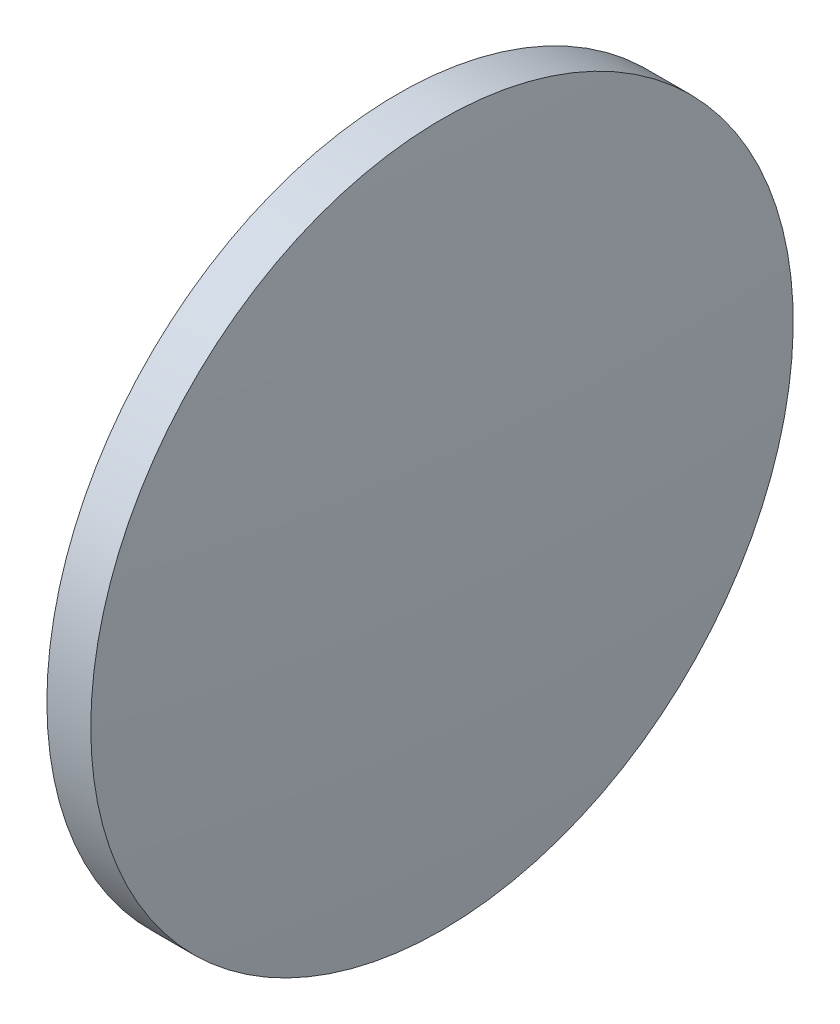
from build123d import *


with BuildPart() as part:
    # 草图1 → 旋转1 (revolve)
    with BuildSketch(Plane.XY, mode=Mode.PRIVATE) as revolve_1_sk:
        with BuildLine():
            Line((564.075425233, 109.277527894), (564.075425233, 129.277527894))
            Line((564.075425233, 129.277527894), (566.575425233, 129.277527894))
            ThreePointArc((566.575425233, 129.277527894), (567.16035114, 119.285130005), (567.355425233, 109.277527894))
            Line((567.355425233, 109.277527894), (564.075425233, 109.277527894))
        make_face()
    revolve(revolve_1_sk.sketch.rotate(Axis((554.568927913, 109.277527894, 0), (1, 0, 0)), 180), axis=Axis((554.568927913, 109.277527894, 0), (1, 0, 0)))  # turned: the seam where the file's is


solid = part.part
